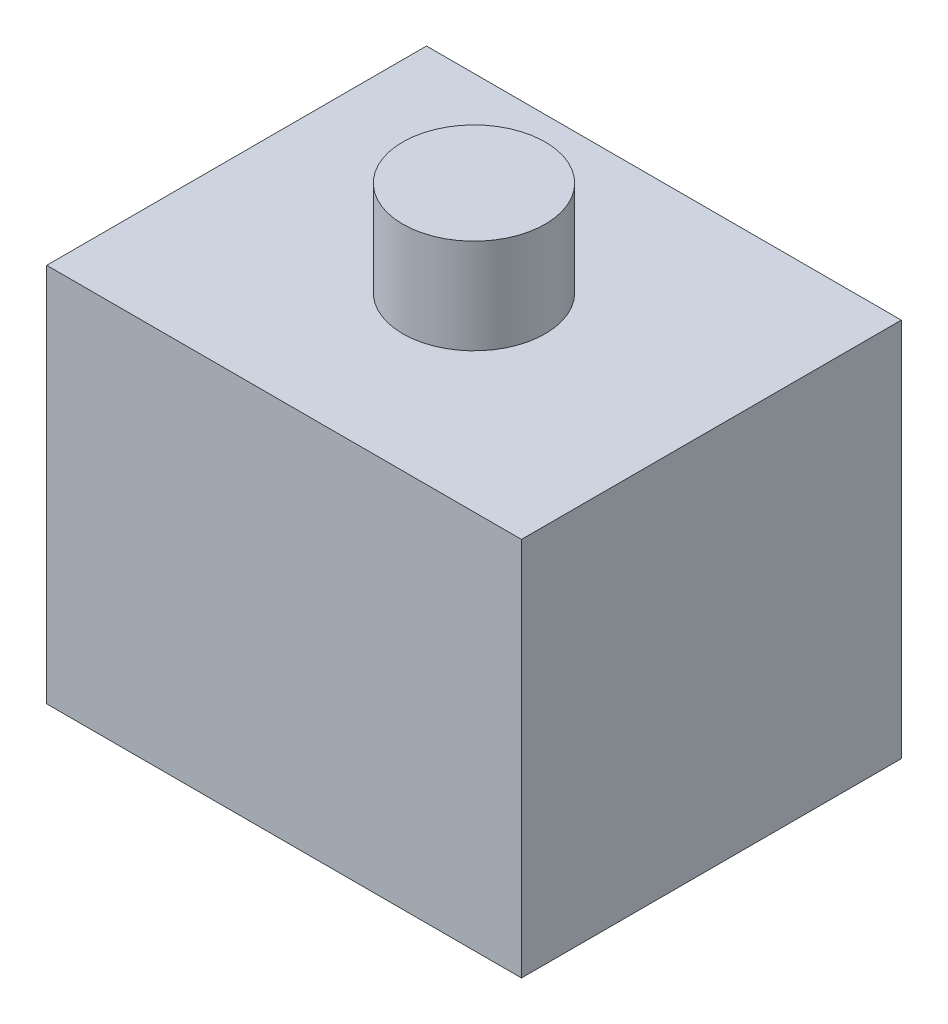
from build123d import *

# Parameters (mm, degrees)
SKETCH_1_W      = 20
SKETCH_1_H      = 16
EXTRUDE_1_DEPTH = 8
SKETCH_2_R      = 6
EXTRUDE_2_DEPTH = 2
SKETCH_3_R      = 4
EXTRUDE_3_DEPTH = 4
SKETCH_4_R      = 3
EXTRUDE_4_DEPTH = 4


with BuildPart() as part:
    # 草图1 → 凸台-拉伸1 (new body, symmetric)
    with BuildSketch(Plane(origin=(0, 0, 0), x_dir=(1, 0, 0), z_dir=(0, 1, 0))):
        Rectangle(SKETCH_1_W, SKETCH_1_H)
    extrude(amount=EXTRUDE_1_DEPTH, both=True)

    # 草图2 → 凸台-拉伸2 (add)
    with BuildSketch(Plane(origin=(0, 0, -8), x_dir=(-1, 0, 0), z_dir=(0, 0, -1))):
        Circle(SKETCH_2_R)
    extrude(amount=EXTRUDE_2_DEPTH)

    # 草图3 → 凸台-拉伸3 (add)
    with BuildSketch(Plane.XZ.offset(8)):
        Circle(SKETCH_3_R)
    extrude(amount=EXTRUDE_3_DEPTH)

    # 草图4 → 凸台-拉伸4 (add)
    with BuildSketch(Plane(origin=(0, 8, 0), x_dir=(1, 0, 0), z_dir=(0, 1, 0))):
        Circle(SKETCH_4_R)
    extrude(amount=EXTRUDE_4_DEPTH)


solid = part.part
